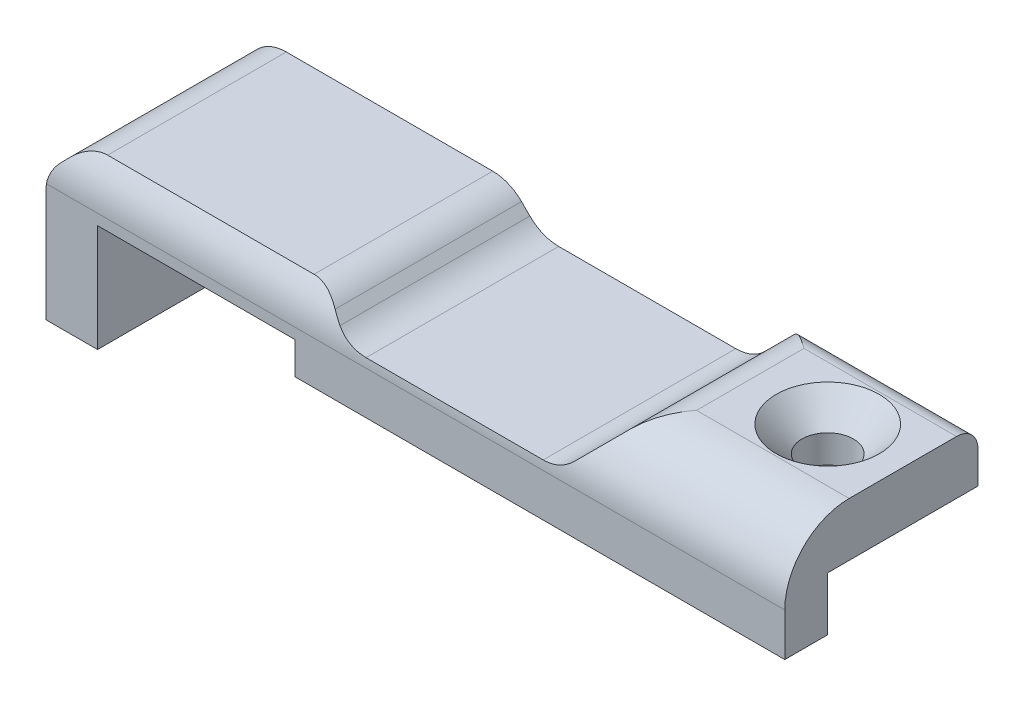
from build123d import *

# Parameters (mm, degrees)
BOSS_EXTRUDE1_DEPTH     = 11.43
SKETCH2_W               = 8.89
SKETCH2_H               = 3.175
BOSS_EXTRUDE2_DEPTH     = 2.54
SKETCH3_R               = 1.524
CUT_EXTRUDE1_DEPTH      = 11.795
CUT_EXTRUDE2_DEPTH      = 1
CUT_EXTRUDE2_DEPTH_BACK = 44.701
CHAMFER1_SIZE           = 1.524


with BuildPart() as part:
    # Sketch1 → Boss-Extrude1 (new body)
    with BuildSketch(Plane.XY):
        with BuildLine():
            Line((-20.079, 0), (-20.079, 1.905))
            Line((-20.079, 1.905), (-31.763, 1.905))
            Line((-31.763, 1.905), (-31.763, -4.445))
            Line((-31.763, -4.445), (-34.811, -4.445))
            Line((-34.811, -4.445), (-34.811, 2.168459549))
            ThreePointArc((-34.811, 2.168459549), (-34.627401057, 3.091473766), (-34.104555503, 3.873967435))
            Line((-34.104555503, 3.873967435), (-33.731967435, 4.246555503))
            ThreePointArc((-33.731967435, 4.246555503), (-32.949473766, 4.769401057), (-32.026459549, 4.953))
            Line((-32.026459549, 4.953), (-19.817153407, 4.953))
            ThreePointArc((-19.817153407, 4.953), (-18.89413919, 4.769401057), (-18.11164552, 4.246555503))
            Line((-18.11164552, 4.246555503), (-17.619534515, 3.754444497))
            ThreePointArc((-17.619534515, 3.754444497), (-16.837040845, 3.231598943), (-15.914026628, 3.048))
            Line((-15.914026628, 3.048), (-5.436586327, 3.048))
            ThreePointArc((-5.436586327, 3.048), (-4.51357211, 3.231598943), (-3.731078441, 3.754444497))
            Line((-3.731078441, 3.754444497), (-1.841967435, 5.643555503))
            ThreePointArc((-1.841967435, 5.643555503), (-1.059473766, 6.166401057), (-0.136459549, 6.35))
            Line((-0.136459549, 6.35), (8.89, 6.35))
            Line((8.89, 6.35), (8.89, 3.175))
            Line((8.89, 3.175), (0, 3.175))
            Line((0, 3.175), (0, 0))
            Line((0, 0), (-20.079, 0))
        make_face()
    extrude(amount=BOSS_EXTRUDE1_DEPTH)

    # Sketch2 → Boss-Extrude2 (add)
    with BuildSketch(Plane.XY.offset(11.43)):
        with Locations((4.445, 1.5875)):
            Rectangle(SKETCH2_W, SKETCH2_H)
    extrude(amount=-BOSS_EXTRUDE2_DEPTH)

    # Sketch3 → Cut-Extrude1 (cut, through all)
    with BuildSketch(Plane(origin=(0, 6.35, 0), x_dir=(1, 0, 0), z_dir=(0, 1, 0))):
        with Locations((4.445, -4.445)):
            Circle(SKETCH3_R)
    extrude(amount=-CUT_EXTRUDE1_DEPTH, mode=Mode.SUBTRACT)

    # Sketch4 → Cut-Extrude2 (cut, two sides)
    with BuildSketch(Plane(origin=(8.89, 0, 0), x_dir=(0, 0, -1), z_dir=(1, 0, 0))) as cut_extrude2_sk:
        with BuildLine():
            Line((-11.43, 3.175), (-11.43, 2.54))
            ThreePointArc((-11.43, 2.54), (-10.314076836, 5.234076836), (-7.62, 6.35))
            Line((-7.62, 6.35), (-11.43, 6.35))
            Line((-11.43, 6.35), (-11.43, 3.175))
        make_face()
        with BuildLine():
            Line((0, 6.35), (-1.27, 6.35))
            ThreePointArc((-1.27, 6.35), (-0.371974388, 5.978025612), (0, 5.08))
            Line((0, 5.08), (0, 6.35))
        make_face()
    extrude(amount=CUT_EXTRUDE2_DEPTH, mode=Mode.SUBTRACT)
    extrude(cut_extrude2_sk.sketch, amount=-CUT_EXTRUDE2_DEPTH_BACK, mode=Mode.SUBTRACT)

    # Chamfer1
    chamfer1_edges = [part.edges().sort_by_distance(p)[0] for p in [
        (2.921, 6.35, 4.445),
    ]]
    chamfer(chamfer1_edges, length=CHAMFER1_SIZE)


solid = part.part
